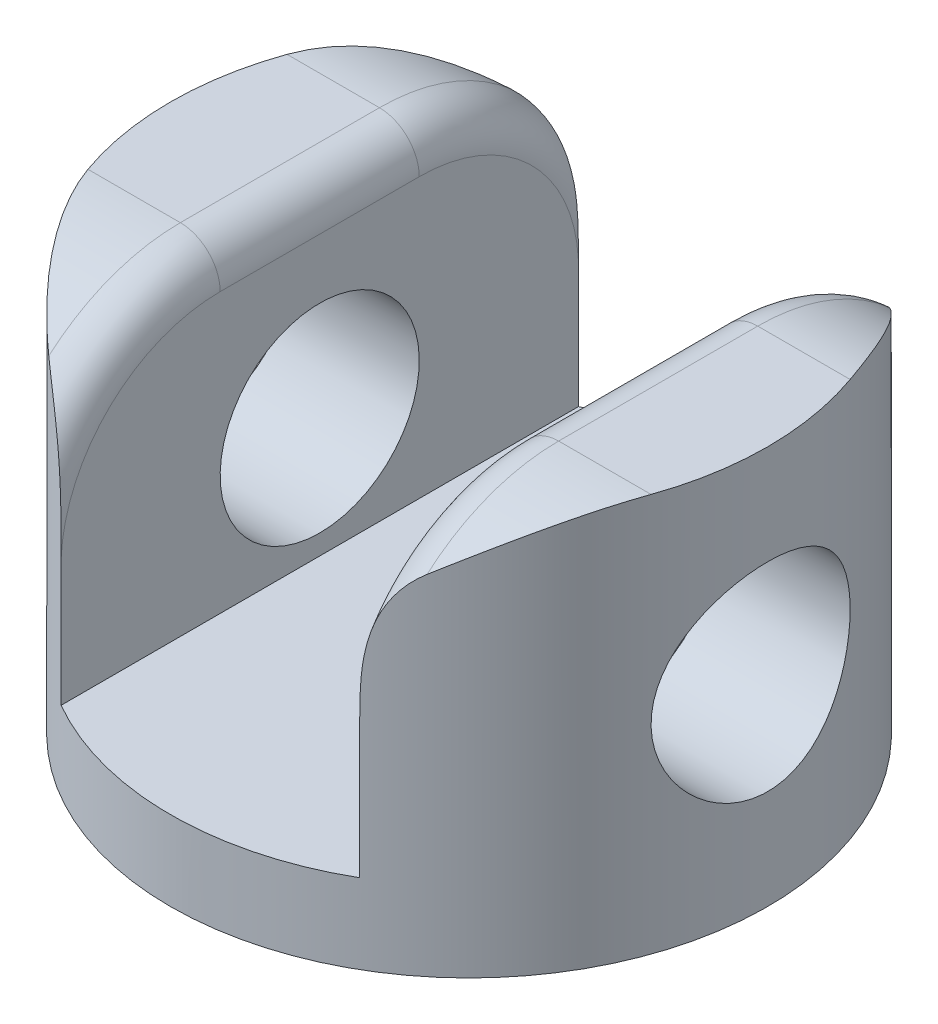
from build123d import *

# Parameters (mm, degrees)
SKETCH1_R               = 15
BOSS_EXTRUDE1_DEPTH     = 20
SKETCH2_R               = 5
CUT_EXTRUDE1_DEPTH      = 16
CUT_EXTRUDE1_DEPTH_BACK = 16
SKETCH3_W               = 15
SKETCH3_H               = 16
CUT_EXTRUDE2_DEPTH      = 16.0000001
CUT_EXTRUDE2_DEPTH_BACK = 16.0000001
FILLET1_R               = 2


with BuildPart() as part:
    # Sketch1 → Boss-Extrude1 (new body)
    with BuildSketch(Plane(origin=(0, 0, 0), x_dir=(1, 0, 0), z_dir=(0, 1, 0))):
        Circle(SKETCH1_R)
    extrude(amount=BOSS_EXTRUDE1_DEPTH)

    # Sketch2 → Cut-Extrude1 (cut, two sides)
    with BuildSketch(Plane(origin=(0, 0, 0), x_dir=(0, 0, -1), z_dir=(1, 0, 0))) as cut_extrude1_sk:
        with BuildLine():
            ThreePointArc((-15, 10), (-12.071067812, 17.071067812), (-5, 20))
            Line((-5, 20), (-15, 20))
            Line((-15, 20), (-15, 10))
        make_face()
        with BuildLine():
            Line((15, 20), (5, 20))
            ThreePointArc((5, 20), (12.071067812, 17.071067812), (15, 10))
            Line((15, 10), (15, 20))
        make_face()
        with Locations((0, 10)):
            Circle(SKETCH2_R)
    extrude(amount=CUT_EXTRUDE1_DEPTH, mode=Mode.SUBTRACT)
    extrude(cut_extrude1_sk.sketch, amount=-CUT_EXTRUDE1_DEPTH_BACK, mode=Mode.SUBTRACT)

    # Sketch3 → Cut-Extrude2 (cut, two sides)
    with BuildSketch(Plane.XY) as cut_extrude2_sk:
        with Locations((0, 12)):
            Rectangle(SKETCH3_W, SKETCH3_H)
    extrude(amount=CUT_EXTRUDE2_DEPTH, mode=Mode.SUBTRACT)
    extrude(cut_extrude2_sk.sketch, amount=-CUT_EXTRUDE2_DEPTH_BACK, mode=Mode.SUBTRACT)

    # Fillet1
    fillet1_edges = [part.edges().sort_by_distance(p)[0] for p in [
        (7.5, 20, 0),
        (-7.5, 20, 0),
        (7.5, 18.947849992, -9.464972622),
        (7.5, 18.94784999, 9.464972627),
        (-7.5, 18.94784999, -9.464972627),
        (-7.5, 18.947849992, 9.464972622),
    ]]
    fillet(fillet1_edges, radius=FILLET1_R)


solid = part.part
